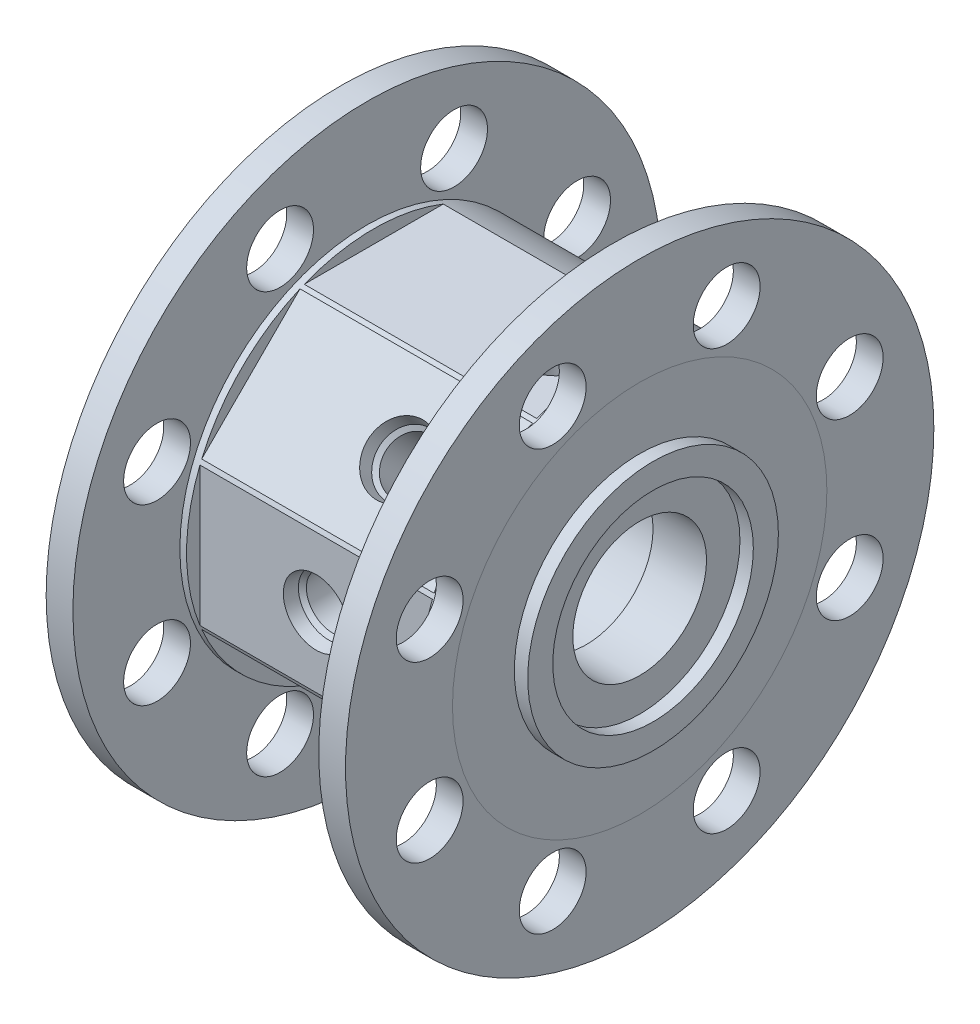
from build123d import *

# Parameters (mm, degrees)
SKETCH2_R                      = 23.8125
SKETCH2_R_2                    = 19.05
LOX_SIDE_HEATSHRINK_RING_DEPTH = 2.54
SKETCH3_R                      = 23.8125
SKETCH3_R_2                    = 19.05
FUEL_HEATSHRINK_RING_DEPTH     = 2.54
CUT_EXTRUDE3_START             = 33.02
SKETCH10_W                     = 44.1630054
SKETCH10_H                     = 71.12
CUT_EXTRUDE3_DEPTH             = 5.08
CIRPATTERN1_COUNT              = 5
CIRPATTERN1_ANGLE              = 180
SKETCH37_R                     = 55.88
SKETCH37_R_2                   = 35.56
BOSS_EXTRUDE1_DEPTH            = 5.08
SKETCH38_R                     = 55.88
SKETCH38_R_2                   = 35.56
BOSS_EXTRUDE2_DEPTH            = 5.08
CIRPATTERN2_COUNT              = 8
CIRPATTERN3_COUNT              = 8


with BuildPart() as part:
    # Sketch1 → Revolve1 (revolve)
    with BuildSketch(Plane.XY):
        Polygon((46.7030054, 15.24), (10.0000054, 15.24), (10.0000054, 15.9999934), (0, 15.9999934), (0, 35.56), (56.8630054, 35.56), (56.8630054, 12.7), (46.7030054, 12.7), align=None)
    revolve(axis=Axis((0, 0, 0), (-1, 0, 0)))

    # Sketch2 → lox side heatshrink ring (add)
    with BuildSketch(Plane.ZY):
        Circle(SKETCH2_R)
        Circle(SKETCH2_R_2, mode=Mode.SUBTRACT)
    extrude(amount=LOX_SIDE_HEATSHRINK_RING_DEPTH)

    # Sketch3 → fuel heatshrink ring (add)
    with BuildSketch(Plane(origin=(56.8630054, 0, 0), x_dir=(0, 0, -1), z_dir=(1, 0, 0))):
        Circle(SKETCH3_R)
        Circle(SKETCH3_R_2, mode=Mode.SUBTRACT)
    extrude(amount=FUEL_HEATSHRINK_RING_DEPTH)

    # Sketch10 → Cut-Extrude3 (cut)
    with BuildSketch(Plane(origin=(0, 0, 0), x_dir=(1, 0, 0), z_dir=(0, 1, 0)).offset(CUT_EXTRUDE3_START)):
        with Locations((28.4315027, 0)):
            Rectangle(SKETCH10_W, SKETCH10_H)
    cut_extrude3 = extrude(amount=CUT_EXTRUDE3_DEPTH, mode=Mode.SUBTRACT)

    # CirPattern1: Cut-Extrude3 ×5 about axis
    cirpattern1_axis = Axis((0, 0, 0), (1, 0, 0))
    for i in range(1, CIRPATTERN1_COUNT):
        add(cut_extrude3.rotate(cirpattern1_axis, i * CIRPATTERN1_ANGLE / (CIRPATTERN1_COUNT - 1)), mode=Mode.SUBTRACT)

    # Sketch16 → fuel recycle port (revolve, cut)
    with BuildSketch(Plane.ZY.offset(-40.8610054)):
        with BuildLine():
            Line((0, 33.02), (-6.223, 33.02))
            Line((-6.223, 33.02), (-5.72089889, 30.6578))
            Line((-5.72089889, 30.6578), (-4.9609375, 29.89783861))
            Line((-4.9609375, 29.89783861), (-4.9609375, 19.1262))
            Line((-4.9609375, 19.1262), (-2.159, 17.965599487))
            Line((-2.159, 17.965599487), (-2.159, 15.086295735))
            ThreePointArc((-2.159, 15.086295735), (-1.082232184, 15.201525368), (0, 15.24))
            Line((0, 15.24), (0, 33.02))
        make_face()
    revolve(axis=Axis((40.8610054, 15.24, 0), (0, 1, 0)), mode=Mode.SUBTRACT)

    # Sketch18 → fuel drain port (revolve, cut)
    with BuildSketch(Plane.ZY.offset(-34.6380054)):
        with BuildLine():
            Line((23.348665915, 23.348665915), (18.948340415, 27.748991414))
            Line((18.948340415, 27.748991414), (17.633051877, 25.723624676))
            Line((17.633051877, 25.723624676), (17.633051877, 24.648876971))
            Line((17.633051877, 24.648876971), (10.016353171, 17.032178266))
            Line((10.016353171, 17.032178266), (11.176953684, 14.230240766))
            Line((11.176953684, 14.230240766), (9.140978477, 12.194265558))
            ThreePointArc((9.140978477, 12.194265558), (9.983847956, 11.514355388), (10.776307345, 10.776307345))
            Line((10.776307345, 10.776307345), (23.348665915, 23.348665915))
        make_face()
    revolve(axis=Axis((34.6380054, 10.776307345, 10.776307345), (0, 0.707106781, 0.707106781)), mode=Mode.SUBTRACT)

    # Sketch34 → Cut-Revolve3 (revolve, cut)
    with BuildSketch(Plane.ZY.offset(-28.4150054)):
        with BuildLine():
            Line((33.02, 0), (33.02, 6.223))
            Line((33.02, 6.223), (30.6578, 5.72089889))
            Line((30.6578, 5.72089889), (29.89783861, 4.9609375))
            Line((29.89783861, 4.9609375), (19.1262, 4.9609375))
            Line((19.1262, 4.9609375), (17.965599487, 2.159))
            Line((17.965599487, 2.159), (15.086295735, 2.159))
            ThreePointArc((15.086295735, 2.159), (15.201525368, 1.082232184), (15.24, 0))
            Line((15.24, 0), (33.02, 0))
        make_face()
    revolve(axis=Axis((28.4150054, 0, 15.24), (0, 0, 1)), mode=Mode.SUBTRACT)

    # Sketch35 → Cut-Revolve4 (revolve, cut)
    with BuildSketch(Plane.ZY.offset(-22.1920054)):
        with BuildLine():
            Line((23.348665915, -23.348665915), (27.748991414, -18.948340415))
            Line((27.748991414, -18.948340415), (25.723624676, -17.633051877))
            Line((25.723624676, -17.633051877), (24.648876971, -17.633051877))
            Line((24.648876971, -17.633051877), (17.032178266, -10.016353171))
            Line((17.032178266, -10.016353171), (14.230240766, -11.176953684))
            Line((14.230240766, -11.176953684), (12.194265558, -9.140978477))
            ThreePointArc((12.194265558, -9.140978477), (11.514355388, -9.983847956), (10.776307345, -10.776307345))
            Line((10.776307345, -10.776307345), (23.348665915, -23.348665915))
        make_face()
    revolve(axis=Axis((22.1920054, -10.776307345, 10.776307345), (0, -0.707106781, 0.707106781)), mode=Mode.SUBTRACT)

    # Sketch36 → Cut-Revolve5 (revolve, cut)
    with BuildSketch(Plane.ZY.offset(-15.9690054)):
        with BuildLine():
            Line((0, -33.02), (6.223, -33.02))
            Line((6.223, -33.02), (5.72089889, -30.6578))
            Line((5.72089889, -30.6578), (4.9609375, -29.89783861))
            Line((4.9609375, -29.89783861), (4.9609375, -19.1262))
            Line((4.9609375, -19.1262), (2.159, -17.965599487))
            Line((2.159, -17.965599487), (2.159, -15.086295735))
            ThreePointArc((2.159, -15.086295735), (1.082232184, -15.201525368), (0, -15.24))
            Line((0, -15.24), (0, -33.02))
        make_face()
    revolve(axis=Axis((15.9690054, -15.24, 0), (0, -1, 0)), mode=Mode.SUBTRACT)

    # Sketch38 → Boss-Extrude2 (add)
    with BuildSketch(Plane.ZY):
        Circle(SKETCH38_R)
        Circle(SKETCH38_R_2, mode=Mode.SUBTRACT)
    extrude(amount=-BOSS_EXTRUDE2_DEPTH)

    # Sketch41 → 1/2 (0.5) Diameter Hole1 (revolve, cut)
    with BuildSketch(Plane(origin=(0, 39.893118214, 16.52427061), x_dir=(0, 0, 1), z_dir=(0, 1, 0))):
        Polygon((0, 0), (0, 8.895464931), (6.35, 5.08), (6.35, 0), align=None)
    f_1_2_0_5_diameter_hole1 = revolve(axis=Axis((-6.35, 39.893118214, 16.52427061), (1, 0, 0)), mode=Mode.SUBTRACT)

    # CirPattern2: 1/2 (0.5) Diameter Hole1 ×8 about axis
    cirpattern2_axis = Axis((0, 0, 0), (1, 0, 0))
    for i in range(1, CIRPATTERN2_COUNT):
        add(f_1_2_0_5_diameter_hole1.rotate(cirpattern2_axis, i * 360 / CIRPATTERN2_COUNT), mode=Mode.SUBTRACT)


with BuildPart() as body_2:
    # Sketch37 → Boss-Extrude1 (new body)
    with BuildSketch(Plane(origin=(56.8630054, 0, 0), x_dir=(0, 0, -1), z_dir=(1, 0, 0))):
        Circle(SKETCH37_R)
        Circle(SKETCH37_R_2, mode=Mode.SUBTRACT)
    extrude(amount=-BOSS_EXTRUDE1_DEPTH)

    # Sketch43 → 1/2 (0.5) Diameter Hole2 (revolve, cut)
    with BuildSketch(Plane(origin=(56.8630054, 39.893118214, 16.52427061), x_dir=(0, 0, -1), z_dir=(0, 1, 0))):
        Polygon((0, 0), (0, 8.895464931), (6.35, 5.08), (6.35, 0), align=None)
    f_1_2_0_5_diameter_hole2 = revolve(axis=Axis((63.2130054, 39.893118214, 16.52427061), (-1, 0, 0)), mode=Mode.SUBTRACT)

    # CirPattern3: 1/2 (0.5) Diameter Hole2 ×8 about axis
    cirpattern3_axis = Axis((0, 0, 0), (1, 0, 0))
    for i in range(1, CIRPATTERN3_COUNT):
        add(f_1_2_0_5_diameter_hole2.rotate(cirpattern3_axis, i * 360 / CIRPATTERN3_COUNT), mode=Mode.SUBTRACT)


solid = Compound([part.part, body_2.part])
